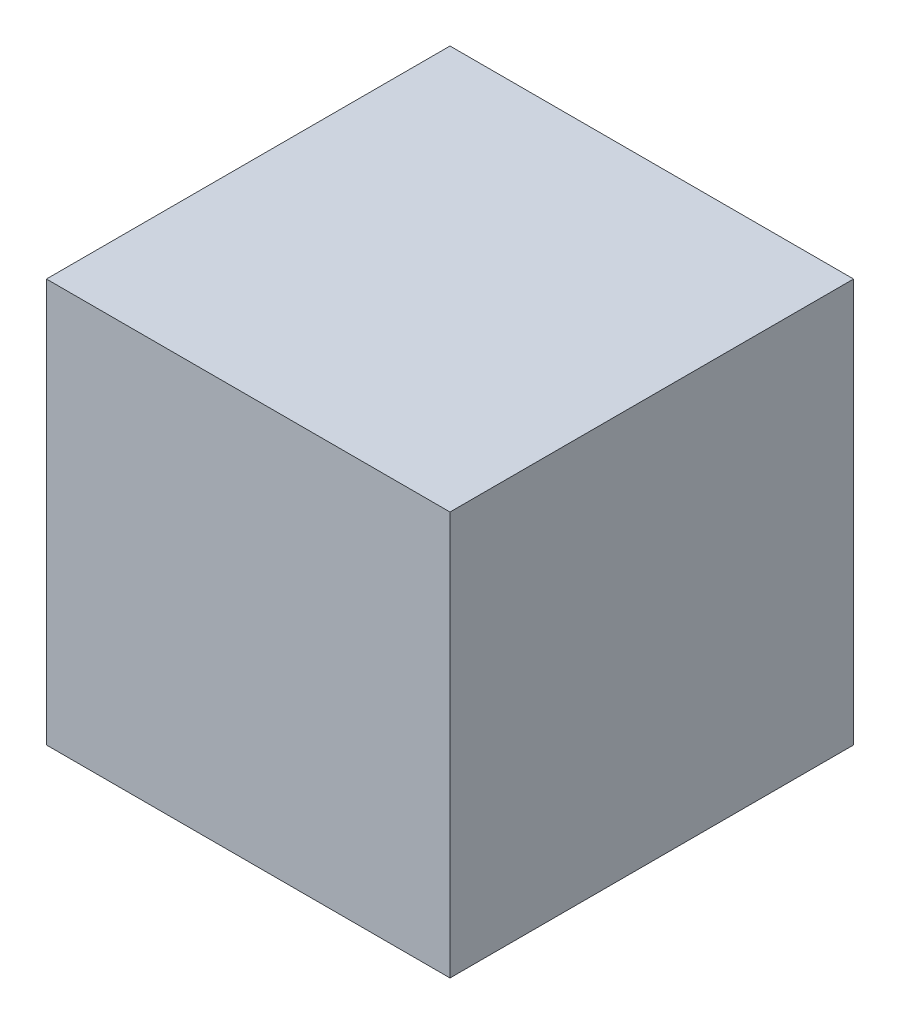
from build123d import *

# Parameters (mm, degrees)
SKETCH_4_W      = 100
SKETCH_4_H      = 100
EXTRUDE_1_DEPTH = 50


with BuildPart() as part:
    # 草图4 → 凸台-拉伸1 (new body, symmetric)
    with BuildSketch(Plane.XY):
        Rectangle(SKETCH_4_W, SKETCH_4_H)
    extrude(amount=EXTRUDE_1_DEPTH, both=True)


solid = part.part
